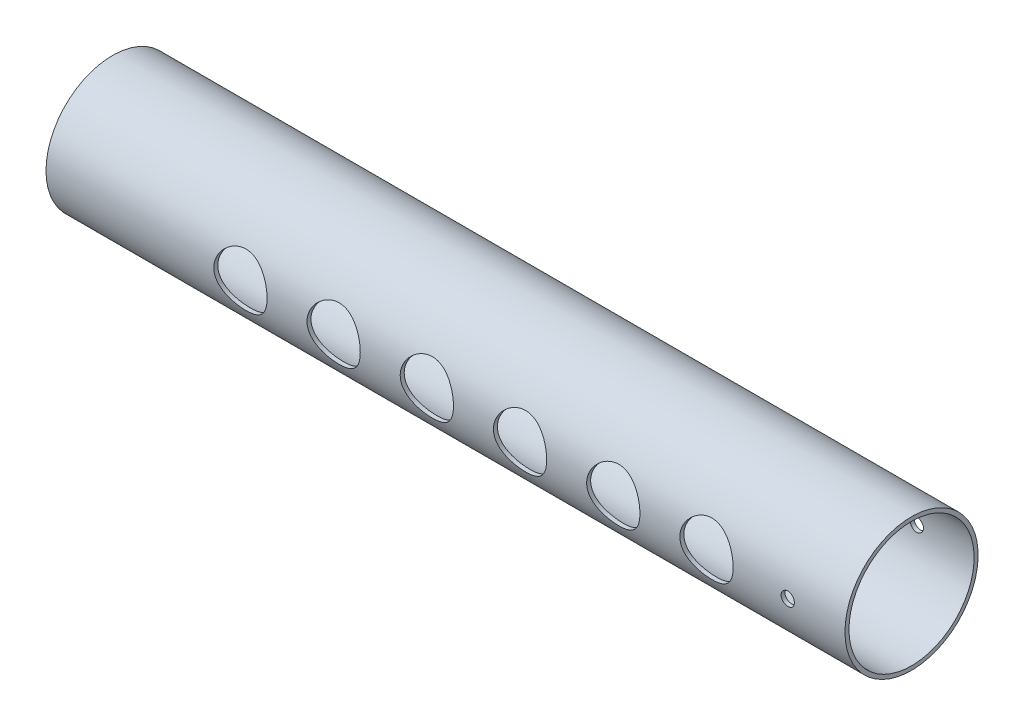
from build123d import *

# Parameters (mm, degrees)
SKETCH110_R                = 25
SKETCH110_R_2              = 23.5
MIEMBRO_ESTRUCTURAL1_DEPTH = 300
CROQUIS2_R                 = 10
CORTAR_EXTRUIR1_DEPTH      = 303.07614934
CORTAR_EXTRUIR1_DEPTH_BACK = 303.07614934
CROQUIS2_3_R               = 10
CORTAR_EXTRUIR2_DEPTH      = 303.076149456
CORTAR_EXTRUIR2_DEPTH_BACK = 303.076149456
CROQUIS3_R                 = 2.5
CORTAR_EXTRUIR3_DEPTH      = 303.076149456
CORTAR_EXTRUIR3_DEPTH_BACK = 303.076149456


with BuildPart() as part:
    # Sketch110 → Miembro estructural1 (new body)
    with BuildSketch(Plane(origin=(0, 0, 0), x_dir=(0, -1, 0), z_dir=(-1, 0, 0))):
        Circle(SKETCH110_R)
        Circle(SKETCH110_R_2, mode=Mode.SUBTRACT)
    extrude(amount=MIEMBRO_ESTRUCTURAL1_DEPTH)

    # Croquis2 → Cortar-Extruir1 (cut, two sides)
    with BuildSketch(Plane.XY) as cortar_extruir1_sk:
        with Locations((-52, 0)):
            Circle(CROQUIS2_R)
    extrude(amount=CORTAR_EXTRUIR1_DEPTH, mode=Mode.SUBTRACT)
    extrude(cortar_extruir1_sk.sketch, amount=-CORTAR_EXTRUIR1_DEPTH_BACK, mode=Mode.SUBTRACT)

    # Croquis2_3 → Cortar-Extruir2 (cut, two sides)
    with BuildSketch(Plane.XY) as cortar_extruir2_sk:
        with Locations((-87, 0)):
            Circle(CROQUIS2_3_R)
        with Locations((-122, 0)):
            Circle(CROQUIS2_3_R)
        with Locations((-157, 0)):
            Circle(CROQUIS2_3_R)
        with Locations((-192, 0)):
            Circle(CROQUIS2_3_R)
        with Locations((-227, 0)):
            Circle(CROQUIS2_3_R)
    extrude(amount=CORTAR_EXTRUIR2_DEPTH, mode=Mode.SUBTRACT)
    extrude(cortar_extruir2_sk.sketch, amount=-CORTAR_EXTRUIR2_DEPTH_BACK, mode=Mode.SUBTRACT)

    # Croquis3 → Cortar-Extruir3 (cut, two sides)
    with BuildSketch(Plane.XY) as cortar_extruir3_sk:
        with Locations((-21.508115169, 0)):
            Circle(CROQUIS3_R)
    extrude(amount=CORTAR_EXTRUIR3_DEPTH, mode=Mode.SUBTRACT)
    extrude(cortar_extruir3_sk.sketch, amount=-CORTAR_EXTRUIR3_DEPTH_BACK, mode=Mode.SUBTRACT)


solid = part.part
